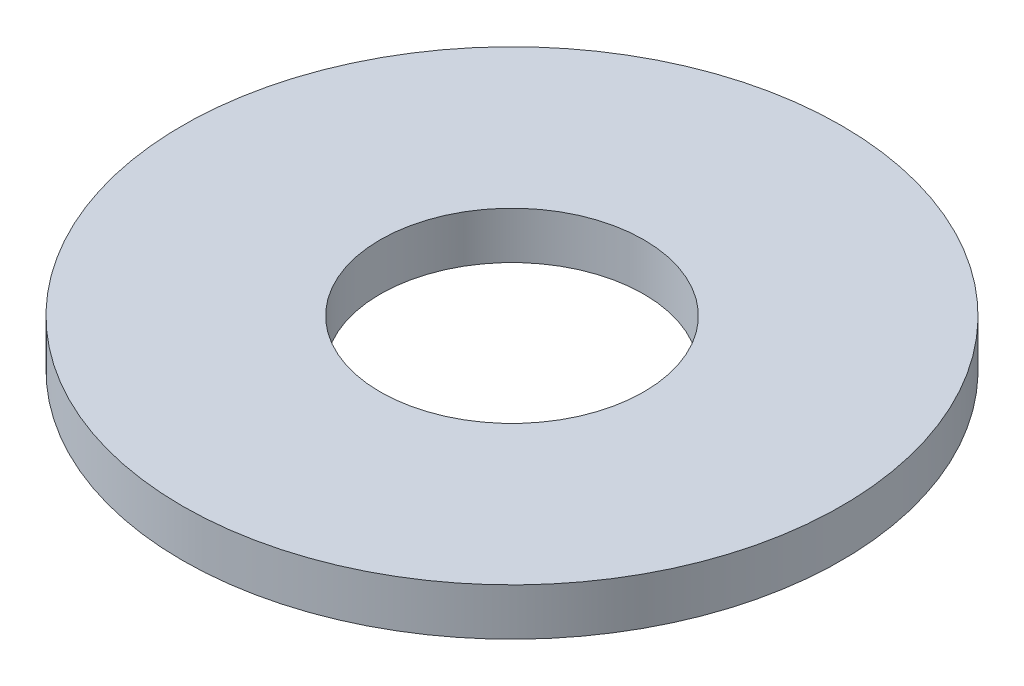
from build123d import *

# Parameters (mm, degrees)
ESQUISSE1_R        = 3.5
ESQUISSE1_R_2      = 1.4
BOSS_EXTRU_1_DEPTH = 0.5


with BuildPart() as part:
    # Esquisse1 → Boss.-Extru.1 (new body)
    with BuildSketch(Plane(origin=(0, 0, 0), x_dir=(1, 0, 0), z_dir=(0, 1, 0))):
        Circle(ESQUISSE1_R)
        Circle(ESQUISSE1_R_2, mode=Mode.SUBTRACT)
    extrude(amount=BOSS_EXTRU_1_DEPTH)


solid = part.part
